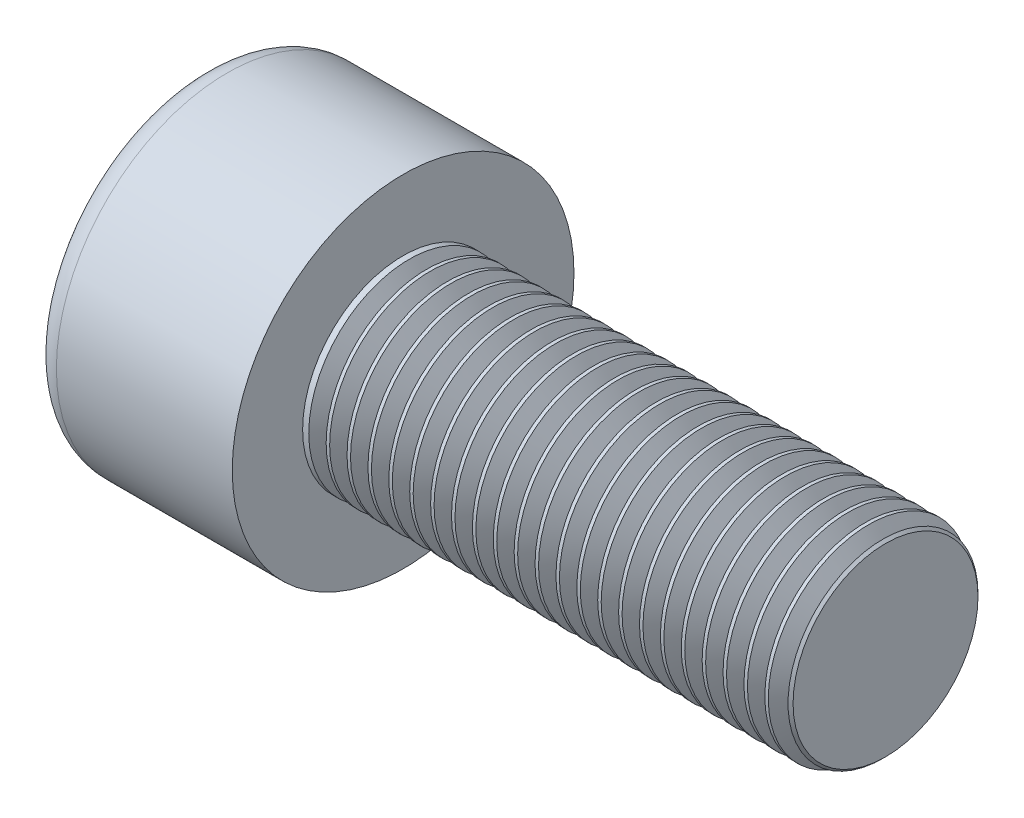
from build123d import *

# Parameters (mm, degrees)
SKETCH1_R           = 4.25
BASEHEAD_DEPTH      = 5
SKETCH2_R           = 2.5
BASEBODY_DEPTH      = 12
HEXAGONSOCKET_DEPTH = 2.5
TOPFILLET_R         = 0.625
CHAMFER1_SIZE       = 0.2
LPATTERN10_COUNT    = 23
LPATTERN10_PITCH    = 0.5196


with BuildPart() as part:
    # Sketch1 → BaseHead (new body)
    with BuildSketch(Plane(origin=(0, 0, 0), x_dir=(0, 0, -1), z_dir=(1, 0, 0))):
        Circle(SKETCH1_R)
    extrude(amount=BASEHEAD_DEPTH)

    # Sketch2 → BaseBody (add)
    with BuildSketch(Plane(origin=(5, 0, 0), x_dir=(0, 0, -1), z_dir=(1, 0, 0))):
        Circle(SKETCH2_R)
    extrude(amount=BASEBODY_DEPTH)

    # Sketch3 → HexagonSocket (cut)
    with BuildSketch(Plane(origin=(0, 0, 0), x_dir=(0, 0, -1), z_dir=(1, 0, 0))):
        Polygon((2.309401077, 0), (1.154700538, 2), (-1.154700538, 2), (-2.309401077, 0), (-1.154700538, -2), (1.154700538, -2), align=None)
    extrude(amount=HEXAGONSOCKET_DEPTH, mode=Mode.SUBTRACT)

    # Sketch4 → Cut-Revolve1 (revolve, cut)
    with BuildSketch(Plane(origin=(-4.19613823, 0.75, 0), x_dir=(-1, 0, 0), z_dir=(0, 0, 1))):
        Polygon((-6.69613823, 2.75), (-7.850838768, 0.75), (-6.69613823, 0.75), align=None)
    revolve(axis=Axis((0.838992387, 0, 0), (-1, 0, 0)), mode=Mode.SUBTRACT)

    # TopFillet
    topfillet_edges = [part.edges().sort_by_distance(p)[0] for p in [
        (0, 0, 4.25),
    ]]
    fillet(topfillet_edges, radius=TOPFILLET_R)

    # Chamfer1
    chamfer1_edges = [part.edges().sort_by_distance(p)[0] for p in [
        (17, 0, 2.5),
    ]]
    chamfer(chamfer1_edges, length=CHAMFER1_SIZE)

    # Sketch5 → Cut-Revolve10 (revolve, cut)
    with BuildSketch(Plane.XY):
        Polygon((16.8, 2.125011), (17.0165, 2.5), (17.0165, 2.933), (16.5835, 2.933), (16.5835, 2.5), align=None)
    cut_revolve10 = revolve(axis=Axis((0, 0, 0), (1, 0, 0)), mode=Mode.SUBTRACT)

    # LPattern10: Cut-Revolve10 ×23
    with Locations(*[(-i * LPATTERN10_PITCH, 0, 0) for i in range(1, LPATTERN10_COUNT)]):
        add(cut_revolve10, mode=Mode.SUBTRACT)


solid = part.part
